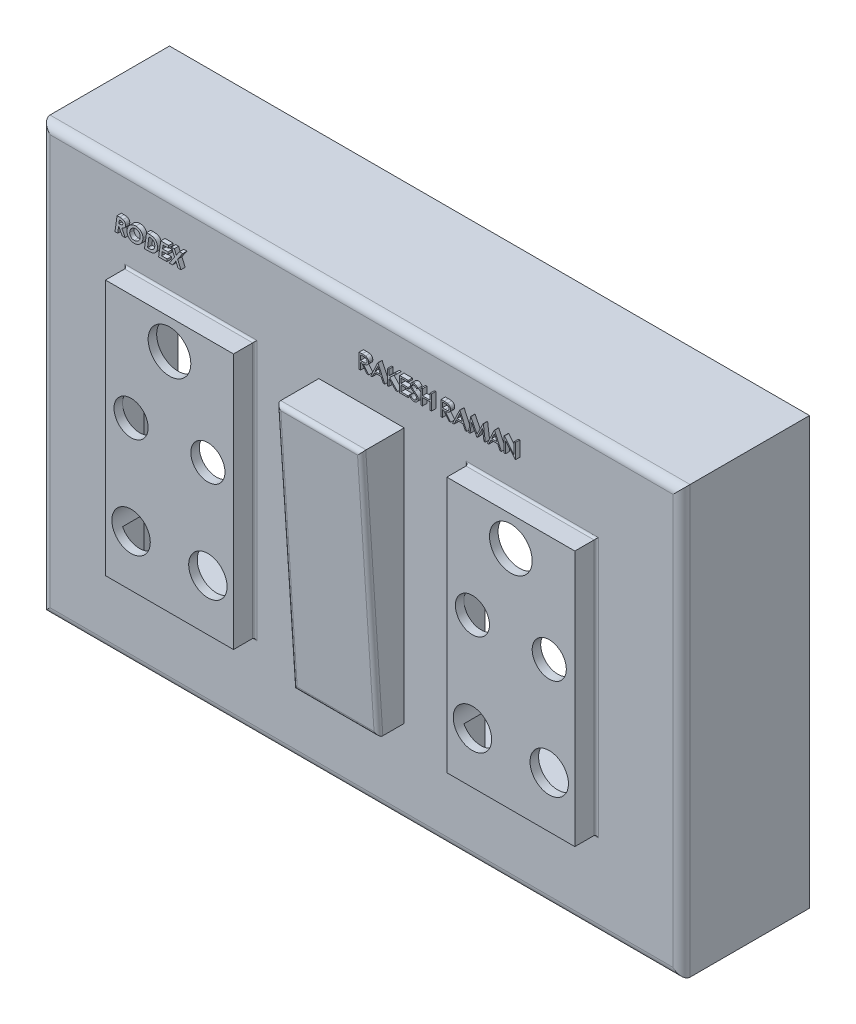
from build123d import *

# Parameters (mm, degrees)
SKETCH1_W           = 150
SKETCH1_H           = 100
BOSS_EXTRUDE1_DEPTH = 30
SKETCH2_W           = 30
SKETCH2_H           = 60
BOSS_EXTRUDE2_DEPTH = 5
LPATTERN1_COUNT     = 2
LPATTERN1_PITCH     = 80
SHELL2_T            = -2
SKETCH3_R           = 5
SKETCH3_R_2         = 4
SKETCH3_R_3         = 4.5
CUT_EXTRUDE1_DEPTH  = 36
BOSS_EXTRUDE3_DEPTH = 10
FILLET1_R           = 2
FILLET2_R           = 0.5
FILLET3_R           = 1
BOSS_EXTRUDE4_DEPTH = 1
BOSS_EXTRUDE5_DEPTH = 1


with BuildPart() as part:
    # Sketch1 → Boss-Extrude1 (new body)
    with BuildSketch(Plane.XY):
        Rectangle(SKETCH1_W, SKETCH1_H)
    extrude(amount=BOSS_EXTRUDE1_DEPTH)

    # Sketch2 → Boss-Extrude2 (add)
    with BuildSketch(Plane.XY.offset(30)):
        with Locations((-40, 0)):
            Rectangle(SKETCH2_W, SKETCH2_H)
    boss_extrude2 = extrude(amount=BOSS_EXTRUDE2_DEPTH)

    # LPattern1: Boss-Extrude2 ×2
    with Locations(*[(i * LPATTERN1_PITCH, 0, 0) for i in range(1, LPATTERN1_COUNT)]):
        add(boss_extrude2)

    # Shell2
    shell2_openings = [part.faces().sort_by_distance(p)[0] for p in [
        (0, 0, 0),
    ]]
    offset(amount=SHELL2_T, openings=shell2_openings, kind=Kind.INTERSECTION)

    # Sketch3 → Cut-Extrude1 (cut)
    with BuildSketch(Plane.XY.offset(35)):
        with Locations((-40, 23)):
            Circle(SKETCH3_R)
        with Locations((-49, 5)):
            Circle(SKETCH3_R_2)
        with Locations((-31, 5)):
            Circle(SKETCH3_R_2)
        with Locations((-49, -18)):
            Circle(SKETCH3_R_3)
        with Locations((-31, -18)):
            Circle(SKETCH3_R_3)
        with Locations((31, 5)):
            Circle(SKETCH3_R_2)
        with Locations((40, 23)):
            Circle(SKETCH3_R)
        with Locations((49, 5)):
            Circle(SKETCH3_R_2)
        with Locations((31, -18)):
            Circle(SKETCH3_R_3)
        with Locations((49, -18)):
            Circle(SKETCH3_R_3)
    extrude(amount=-CUT_EXTRUDE1_DEPTH, mode=Mode.SUBTRACT)

    # Sketch8 → Boss-Extrude3 (add, symmetric)
    with BuildSketch(Plane(origin=(0, 0, 0), x_dir=(0, 0, -1), z_dir=(1, 0, 0))):
        Polygon((-30, 30), (-40, 30), (-36, -30), (-30, -30), align=None)
    extrude(amount=BOSS_EXTRUDE3_DEPTH, both=True)

    # Fillet1
    fillet1_edges = [part.edges().sort_by_distance(p)[0] for p in [
        (-75, 0, 30),
        (0, -50, 30),
        (75, 0, 30),
        (0, 50, 30),
    ]]
    fillet(fillet1_edges, radius=FILLET1_R)

    # Fillet2
    fillet2_edges = [part.edges().sort_by_distance(p)[0] for p in [
        (-25, 0, 30),
        (-40, 30, 30),
        (-55, 0, 30),
        (-40, -30, 30),
        (55, 0, 30),
        (40, 30, 30),
        (25, 0, 30),
        (40, -30, 30),
    ]]
    fillet(fillet2_edges, radius=FILLET2_R)

    # Fillet3
    fillet3_edges = [part.edges().sort_by_distance(p)[0] for p in [
        (-10, 0, 38),
        (0, 30, 40),
        (0, -30, 36),
        (10, 0, 38),
    ]]
    fillet(fillet3_edges, radius=FILLET3_R)

    # Sketch9 → Boss-Extrude4 (add)
    with BuildSketch(Plane.XY.offset(30)):
        Polygon((-43.547393435, 40.422406767), (-42.864500807, 40.422406767), (-42.389841352, 39.346184812), (-41.644548884, 40.422406767), (-40.890842954, 40.422406767), (-42.096071319, 38.681521351), (-41.319929493, 36.922406767), (-42.002120999, 36.922406767), (-42.513238787, 38.079257729), (-43.313919877, 36.922406767), (-44.067625807, 36.922406767), (-42.806307698, 38.743921191), align=None)
        Polygon((-46.053903852, 40.422406767), (-44.16648398, 40.422406767), (-44.240101768, 39.839073434), (-45.501419877, 39.839073434), (-45.615001608, 39.031381126), (-44.341764428, 39.031381126), (-44.416083339, 38.448047793), (-45.697032858, 38.448047793), (-45.828843755, 37.505740101), (-44.534572922, 37.505740101), (-44.608190711, 36.922406767), (-46.544689108, 36.922406767), align=None)
        with BuildLine():
            Line((-49.374416672, 40.422406767), (-48.821932698, 40.422406767))
            add(Edge.make_bspline(
                [(-48.821932698, 40.422406767), (-48.759290387, 40.421889397), (-48.638152322, 40.420888903), (-48.462480874, 40.412639578), (-48.299442504, 40.398079242), (-48.148738887, 40.377926725), (-48.010357772, 40.352215695), (-47.884246306, 40.321082878), (-47.770278799, 40.284251753), (-47.668137679, 40.239998159), (-47.574089919, 40.190339256), (-47.485954252, 40.133676052), (-47.402212683, 40.070716209), (-47.322300496, 40.001858101), (-47.247837539, 39.925589229), (-47.177775921, 39.842713508), (-47.111847466, 39.753410594), (-47.050274592, 39.658607579), (-46.99488923, 39.558371142), (-46.946505843, 39.453604173), (-46.904965724, 39.34530025), (-46.872109833, 39.232864844), (-46.84613627, 39.116935479), (-46.827255044, 38.997060228), (-46.815729294, 38.873389341), (-46.814527877, 38.789752735), (-46.813919877, 38.7474268)],
                knots=[0, 0, 0, 0, 1.508928034, 2.917973822, 4.235011166, 5.450779055, 6.579221784, 7.623755204, 8.577985451, 9.460610614, 10.301756591, 11.137250569, 11.981705789, 12.823774396, 13.675702816, 14.546470419, 15.435981066, 16.347923198, 17.267651715, 18.192054867, 19.125737078, 20.059147693, 21.011116727, 21.985721956, 22.980635317, 24, 24, 24, 24], degree=3))
            add(Edge.make_bspline(
                [(-46.813919877, 38.7474268), (-46.814774157, 38.70369732), (-46.816472156, 38.616778874), (-46.828656039, 38.487976676), (-46.848359824, 38.361782887), (-46.875519412, 38.238241361), (-46.911289505, 38.117302821), (-46.95595236, 37.999604468), (-47.006807136, 37.883969064), (-47.066568068, 37.772774746), (-47.131016482, 37.666011074), (-47.200793477, 37.566182849), (-47.2739781, 37.473397811), (-47.352410576, 37.388928871), (-47.43458433, 37.311572308), (-47.520529875, 37.241329906), (-47.611174378, 37.17917603), (-47.706415878, 37.124006463), (-47.808790036, 37.075645841), (-47.919864089, 37.034677438), (-48.039979404, 36.999465995), (-48.169710895, 36.97197737), (-48.308439698, 36.949536922), (-48.456561442, 36.93346408), (-48.61405927, 36.924665187), (-48.72212911, 36.923174271), (-48.777762025, 36.922406767)],
                knots=[0, 0, 0, 0, 1.035326767, 2.057856534, 3.060426681, 4.057975219, 5.050723532, 6.043595218, 7.036960241, 8.039530388, 9.030318104, 9.988216712, 10.921569661, 11.826132526, 12.714780289, 13.59198308, 14.451536877, 15.31430869, 16.195534129, 17.128821459, 18.114698389, 19.15667332, 20.266554844, 21.441073174, 22.682698532, 24, 24, 24, 24], degree=3))
            Line((-48.777762025, 36.922406767), (-49.865201928, 36.922406767))
            Line((-49.865201928, 36.922406767), (-49.374416672, 40.422406767))
        make_face()
        with BuildLine():
            Line((-48.822633819, 39.839073434), (-49.149356576, 37.505740101))
            Line((-49.149356576, 37.505740101), (-48.922894236, 37.505740101))
            add(Edge.make_bspline(
                [(-48.922894236, 37.505740101), (-48.880821073, 37.505955589), (-48.799924163, 37.506369924), (-48.683066021, 37.511008387), (-48.575191276, 37.516530336), (-48.47635572, 37.526783879), (-48.386198218, 37.538193292), (-48.305331211, 37.553057707), (-48.232824593, 37.569034943), (-48.188711057, 37.584120985), (-48.167786063, 37.59127696)],
                knots=[0, 0, 0, 0, 1.323091274, 2.54399687, 3.677836413, 4.719289959, 5.668358043, 6.534823038, 7.305002022, 8, 8, 8, 8], degree=3))
            add(Edge.make_bspline(
                [(-48.167786063, 37.59127696), (-48.140899852, 37.60172672), (-48.087487917, 37.622486132), (-48.012162341, 37.662867302), (-47.939077552, 37.705666553), (-47.871429396, 37.756008508), (-47.806819913, 37.810655894), (-47.7478338, 37.871943474), (-47.691607404, 37.93761707), (-47.640133478, 38.008941608), (-47.593076254, 38.084773082), (-47.553002495, 38.165704603), (-47.518399787, 38.250660786), (-47.490691839, 38.340343711), (-47.468737841, 38.434045283), (-47.453739247, 38.532043712), (-47.443267845, 38.634319362), (-47.442510501, 38.704163236), (-47.442125005, 38.73971446)],
                knots=[0, 0, 0, 0, 0.952655881, 1.892538673, 2.821337892, 3.750040712, 4.676008024, 5.615700279, 6.558436491, 7.532008524, 8.520486916, 9.505184105, 10.513747313, 11.549809891, 12.604882282, 13.692134403, 14.825273528, 16, 16, 16, 16], degree=3))
            add(Edge.make_bspline(
                [(-47.442125005, 38.73971446), (-47.442527846, 38.768937256), (-47.443315176, 38.826051573), (-47.449501743, 38.909912287), (-47.460968386, 38.990150986), (-47.475976013, 39.06681252), (-47.495922348, 39.139829917), (-47.519690861, 39.209187915), (-47.547380566, 39.275388702), (-47.591695881, 39.357046521), (-47.654863795, 39.452315716), (-47.747138857, 39.55301225), (-47.854370035, 39.639033943), (-47.954320488, 39.699148793), (-48.041548257, 39.740282487), (-48.113185574, 39.766621303), (-48.189991294, 39.789231233), (-48.272098349, 39.806937164), (-48.359022943, 39.82214953), (-48.45135934, 39.831270574), (-48.548862394, 39.838026458), (-48.615789667, 39.838718209), (-48.650157858, 39.839073434)],
                knots=[0, 0, 0, 0, 0.941373656, 1.839862062, 2.706559874, 3.551131217, 4.354742518, 5.142827075, 5.911946928, 6.663057697, 8.133107042, 9.582556681, 11.0440985, 12.547036792, 13.328439944, 14.147940985, 15.003216405, 15.905576335, 16.852443473, 17.844335315, 18.893032825, 20, 20, 20, 20], degree=3))
            Line((-48.650157858, 39.839073434), (-48.822633819, 39.839073434))
        make_face(mode=Mode.SUBTRACT)
        with BuildLine():
            add(Edge.make_bspline(
                [(-51.887938307, 40.512150357), (-51.828973482, 40.510912856), (-51.713197802, 40.508483058), (-51.543495377, 40.486123035), (-51.381595874, 40.450083299), (-51.227893755, 40.398403173), (-51.081798878, 40.333114436), (-50.943662788, 40.252654398), (-50.813636321, 40.157590939), (-50.692778193, 40.04921214), (-50.583303738, 39.929798172), (-50.486222935, 39.801987961), (-50.405598379, 39.665200149), (-50.339201848, 39.520957911), (-50.286861811, 39.36910353), (-50.251158378, 39.208907266), (-50.227591277, 39.041430589), (-50.22532858, 38.926996939), (-50.224176287, 38.86872087)],
                knots=[0, 0, 0, 0, 1.079937363, 2.120424901, 3.130164457, 4.114608815, 5.086352068, 6.057283592, 7.037967613, 8.032612779, 9.026667848, 10.002130715, 10.967845321, 11.92966918, 12.907375778, 13.904589319, 14.932898699, 16, 16, 16, 16], degree=3))
            add(Edge.make_bspline(
                [(-50.224176287, 38.86872087), (-50.224914256, 38.823347653), (-50.226382019, 38.733103842), (-50.240348474, 38.598920423), (-50.262106322, 38.466641272), (-50.291897994, 38.336228211), (-50.331777104, 38.208099516), (-50.379380003, 38.081496037), (-50.436168473, 37.956935761), (-50.501386974, 37.83538348), (-50.572832347, 37.718270982), (-50.651140848, 37.607532431), (-50.73526803, 37.50382504), (-50.824891022, 37.406740524), (-50.920977573, 37.317578589), (-51.021649634, 37.234471365), (-51.129088084, 37.159307899), (-51.24158734, 37.090652264), (-51.359382524, 37.0296357), (-51.481677665, 36.976898587), (-51.608313599, 36.932805542), (-51.738991311, 36.896352114), (-51.87403357, 36.867351248), (-52.013415372, 36.847317452), (-52.157185612, 36.835159151), (-52.254367308, 36.833503634), (-52.303703531, 36.832663178)],
                knots=[0, 0, 0, 0, 1.005311864, 1.999487392, 2.986390894, 3.975195422, 4.961487101, 5.958115224, 6.97104375, 7.992937587, 9.013623077, 10.009524137, 10.996414046, 11.971324635, 12.935123389, 13.899409138, 14.862205298, 15.838449601, 16.81836937, 17.799766407, 18.787539403, 19.787875373, 20.804768927, 21.846385261, 22.906674593, 24, 24, 24, 24], degree=3))
            add(Edge.make_bspline(
                [(-52.303703531, 36.832663178), (-52.364768061, 36.833921598), (-52.484003636, 36.83637881), (-52.657781328, 36.858080815), (-52.822200652, 36.89196513), (-52.977269185, 36.94047307), (-53.123275806, 37.003023262), (-53.259738688, 37.079774766), (-53.386991965, 37.169890765), (-53.5029024, 37.274010014), (-53.608300432, 37.388219062), (-53.6988067, 37.51346756), (-53.776964198, 37.646374147), (-53.83897103, 37.789116583), (-53.888587491, 37.939943218), (-53.923155991, 38.099721681), (-53.944773705, 38.268200553), (-53.94726236, 38.383477002), (-53.948535262, 38.442438819)],
                knots=[0, 0, 0, 0, 1.129126937, 2.20475128, 3.23403939, 4.230775744, 5.204839333, 6.16680792, 7.121629951, 8.083044708, 9.04383724, 9.990659777, 10.936010704, 11.890255174, 12.863608629, 13.868449271, 14.909750384, 16, 16, 16, 16], degree=3))
            add(Edge.make_bspline(
                [(-53.948535262, 38.442438819), (-53.94700596, 38.509834945), (-53.943994684, 38.642541521), (-53.917523901, 38.837884118), (-53.877062598, 39.026442562), (-53.817444786, 39.207214961), (-53.742258443, 39.380887275), (-53.649653055, 39.546881264), (-53.541063492, 39.706542953), (-53.456404006, 39.80479679), (-53.413579332, 39.854498114)],
                knots=[0, 0, 0, 0, 1.045740506, 2.05911896, 3.05467723, 4.035585325, 5.008815224, 5.988058098, 6.982266978, 8, 8, 8, 8], degree=3))
            add(Edge.make_bspline(
                [(-53.413579332, 39.854498114), (-53.388649769, 39.881445822), (-53.339239492, 39.934856052), (-53.26016141, 40.0090792), (-53.179147553, 40.078570119), (-53.095051188, 40.142503863), (-53.009142418, 40.202365344), (-52.920052286, 40.256267874), (-52.828117799, 40.30479636), (-52.734338831, 40.349048024), (-52.637101807, 40.386832196), (-52.538087519, 40.420686836), (-52.435921883, 40.448620076), (-52.331324949, 40.471739845), (-52.22419659, 40.490123098), (-52.114394475, 40.502460586), (-52.002105406, 40.510444616), (-51.926280011, 40.511577504), (-51.887938307, 40.512150357)],
                knots=[0, 0, 0, 0, 1.027812829, 2.037120149, 3.035266778, 4.015768311, 4.994345575, 5.966422343, 6.929711672, 7.904780536, 8.86860337, 9.849672715, 10.834163809, 11.833018336, 12.848777673, 13.876590502, 14.926281379, 16, 16, 16, 16], degree=3))
        make_face()
        with BuildLine():
            add(Edge.make_bspline(
                [(-51.902661864, 39.928817024), (-51.934468876, 39.928341515), (-51.997748676, 39.927395494), (-52.091410195, 39.917881855), (-52.183187476, 39.903141277), (-52.2726949, 39.882940165), (-52.360361901, 39.856868442), (-52.445591612, 39.824648747), (-52.529013746, 39.786517991), (-52.609708584, 39.742519131), (-52.687946826, 39.693454287), (-52.762094746, 39.638697128), (-52.832673739, 39.579031525), (-52.898495837, 39.513405532), (-52.961006455, 39.44316759), (-53.020030604, 39.368175831), (-53.074831094, 39.287699865), (-53.125651665, 39.203078321), (-53.170764142, 39.11500521), (-53.210834054, 39.02619021), (-53.244936146, 38.936620677), (-53.27198113, 38.846053076), (-53.294058846, 38.754850474), (-53.309367715, 38.662772577), (-53.318872989, 38.570012212), (-53.319843905, 38.507899443), (-53.320330134, 38.476793787)],
                knots=[0, 0, 0, 0, 1.015557909, 2.02044445, 3.003357477, 3.982977463, 4.948851735, 5.922052592, 6.890662853, 7.875953625, 8.855459861, 9.837777552, 10.817397539, 11.804383193, 12.803598646, 13.818964529, 14.849984807, 15.911175445, 16.969421976, 18.008462528, 19.021851172, 20.027762868, 21.025304218, 22.016795393, 23.006824523, 24, 24, 24, 24], degree=3))
            add(Edge.make_bspline(
                [(-53.320330134, 38.476793787), (-53.319562512, 38.44052815), (-53.318052176, 38.369173524), (-53.304891358, 38.264135147), (-53.284499951, 38.16300844), (-53.253643325, 38.066631534), (-53.216149774, 37.973962383), (-53.168545797, 37.886385994), (-53.113822605, 37.802170699), (-53.050220609, 37.723455673), (-52.979180754, 37.650780593), (-52.899035485, 37.588080792), (-52.811824072, 37.534542771), (-52.717171954, 37.490977031), (-52.615157118, 37.456974062), (-52.505517228, 37.433868331), (-52.388734727, 37.418557113), (-52.308428814, 37.416864527), (-52.267245198, 37.415996511)],
                knots=[0, 0, 0, 0, 1.032572517, 2.031642993, 3.01079972, 3.966643664, 4.909863955, 5.853952978, 6.801111379, 7.766917104, 8.731873648, 9.689385086, 10.65752794, 11.640388645, 12.650815691, 13.713650281, 14.827481725, 16, 16, 16, 16], degree=3))
            add(Edge.make_bspline(
                [(-52.267245198, 37.415996511), (-52.219036144, 37.417135556), (-52.123842293, 37.419384721), (-51.984019218, 37.439417341), (-51.849795446, 37.472672277), (-51.721159455, 37.518115565), (-51.598069804, 37.576932899), (-51.480523442, 37.648718234), (-51.368823664, 37.73415636), (-51.263869016, 37.831012497), (-51.167455615, 37.93672827), (-51.083177299, 38.049710473), (-51.011604854, 38.168471614), (-50.953292589, 38.292751995), (-50.908174393, 38.422760808), (-50.876011253, 38.558269632), (-50.855714418, 38.699369501), (-50.853501841, 38.795501427), (-50.852381416, 38.844181607)],
                knots=[0, 0, 0, 0, 1.03369803, 2.041145535, 3.022357397, 3.995919545, 4.96236968, 5.943376615, 6.945032455, 7.973917545, 9.003120129, 10.009769043, 10.992465341, 11.972511115, 12.949140339, 13.93890809, 14.956285095, 16, 16, 16, 16], degree=3))
            add(Edge.make_bspline(
                [(-50.852381416, 38.844181607), (-50.853027787, 38.884191879), (-50.85429453, 38.962602983), (-50.868920783, 39.076782215), (-50.891138573, 39.185004447), (-50.922370895, 39.287236229), (-50.964438443, 39.382902417), (-51.01379099, 39.47318065), (-51.073560722, 39.556539334), (-51.141292992, 39.633254071), (-51.216176709, 39.702960503), (-51.297856902, 39.763061959), (-51.384557445, 39.815244394), (-51.477761173, 39.855954747), (-51.575781577, 39.889721393), (-51.679773999, 39.912422897), (-51.789428773, 39.925829268), (-51.864295063, 39.927804682), (-51.902661864, 39.928817024)],
                knots=[0, 0, 0, 0, 1.12845219, 2.211511647, 3.242392028, 4.243671568, 5.221368115, 6.186708094, 7.141970352, 8.109200861, 9.070590294, 10.022934043, 10.966237583, 11.91979086, 12.887493425, 13.887534174, 14.917422563, 16, 16, 16, 16], degree=3))
        make_face(mode=Mode.SUBTRACT)
        with BuildLine():
            Line((-56.284673082, 40.422406767), (-55.676800486, 40.422406767))
            add(Edge.make_bspline(
                [(-55.676800486, 40.422406767), (-55.631689768, 40.422222419), (-55.54471088, 40.421866974), (-55.41963241, 40.416812548), (-55.304831654, 40.409186975), (-55.200445114, 40.399123522), (-55.106385638, 40.385161044), (-55.022848829, 40.368396292), (-54.949301119, 40.349726404), (-54.905194816, 40.332377127), (-54.884532858, 40.324249716)],
                knots=[0, 0, 0, 0, 1.348808202, 2.600664361, 3.742342956, 4.788858012, 5.735658768, 6.584006912, 7.336666444, 8, 8, 8, 8], degree=3))
            add(Edge.make_bspline(
                [(-54.884532858, 40.324249716), (-54.86127015, 40.313759346), (-54.815795237, 40.293252333), (-54.750632337, 40.258491686), (-54.689612353, 40.221045036), (-54.633746582, 40.179500521), (-54.581856083, 40.135607447), (-54.534262624, 40.088948332), (-54.491349433, 40.038807103), (-54.452666143, 39.98608311), (-54.418269129, 39.930844544), (-54.388742837, 39.872819007), (-54.363211963, 39.81249776), (-54.343274467, 39.749224402), (-54.326704011, 39.683758458), (-54.315986841, 39.615686882), (-54.308444602, 39.545239292), (-54.307824861, 39.497414587), (-54.307509621, 39.473087857)],
                knots=[0, 0, 0, 0, 1.116361014, 2.182309107, 3.229450697, 4.24598407, 5.225421932, 6.201651319, 7.158895679, 8.110002388, 9.060669178, 10.002827475, 10.956240434, 11.923213192, 12.902917952, 13.908279153, 14.936015885, 16, 16, 16, 16], degree=3))
            add(Edge.make_bspline(
                [(-54.307509621, 39.473087857), (-54.308250987, 39.443152142), (-54.309714563, 39.384054195), (-54.319277878, 39.296906321), (-54.33711465, 39.213278889), (-54.361135401, 39.132908464), (-54.390895184, 39.055274657), (-54.429274317, 38.981728354), (-54.473635822, 38.910988101), (-54.524868834, 38.843981348), (-54.582134059, 38.780093417), (-54.648255331, 38.723084184), (-54.719574727, 38.669119618), (-54.799022149, 38.621817803), (-54.884412596, 38.577878629), (-54.977693704, 38.540650691), (-55.077114731, 38.50629505), (-55.146826943, 38.48910053), (-55.182509621, 38.480299396)],
                knots=[0, 0, 0, 0, 0.995453645, 1.965186658, 2.910129054, 3.83459069, 4.752398018, 5.669942118, 6.588407184, 7.525617038, 8.471772905, 9.435289717, 10.423772802, 11.441988612, 12.505459691, 13.613754905, 14.778583949, 16, 16, 16, 16], degree=3))
            Line((-55.182509621, 38.480299396), (-54.374817313, 36.922406767))
            Line((-54.374817313, 36.922406767), (-55.07664023, 36.922406767))
            Line((-55.07664023, 36.922406767), (-55.867505614, 38.448047793))
            Line((-55.867505614, 38.448047793), (-55.927100967, 38.448047793))
            Line((-55.927100967, 38.448047793), (-56.141644236, 36.922406767))
            Line((-56.141644236, 36.922406767), (-56.775458339, 36.922406767))
            Line((-56.775458339, 36.922406767), (-56.284673082, 40.422406767))
        make_face()
        with BuildLine():
            add(Edge.make_bspline(
                [(-55.845069717, 39.031381126), (-55.799957643, 39.031800016), (-55.713669594, 39.032601247), (-55.590433204, 39.038174389), (-55.479302411, 39.046977929), (-55.380597716, 39.059558763), (-55.294059473, 39.074437337), (-55.220055301, 39.093012173), (-55.158245998, 39.115097316), (-55.107656675, 39.141288089), (-55.066675838, 39.172038612), (-55.031205164, 39.20485424), (-55.001669446, 39.241587703), (-54.977299831, 39.281622322), (-54.95850435, 39.325041078), (-54.944949903, 39.372138126), (-54.937455542, 39.422599442), (-54.936303444, 39.457405922), (-54.935714749, 39.475191223)],
                knots=[0, 0, 0, 0, 1.892208387, 3.619318591, 5.173427176, 6.566868293, 7.791773198, 8.8545744, 9.763297566, 10.539470204, 11.233547833, 11.906251103, 12.5615143, 13.203742025, 13.866659999, 14.539934446, 15.25394049, 16, 16, 16, 16], degree=3))
            add(Edge.make_bspline(
                [(-54.935714749, 39.475191223), (-54.936476792, 39.495357186), (-54.93795505, 39.53447639), (-54.950741384, 39.590819324), (-54.972605574, 39.641930019), (-55.003332714, 39.687319831), (-55.041678533, 39.727342321), (-55.08845833, 39.760305458), (-55.143137568, 39.786253789), (-55.194358971, 39.803397065), (-55.242842714, 39.81332689), (-55.288038904, 39.819998402), (-55.341549931, 39.826436173), (-55.403536753, 39.831196702), (-55.473924853, 39.834345703), (-55.552678396, 39.837405635), (-55.639638504, 39.838493764), (-55.700405077, 39.838874362), (-55.732189108, 39.839073434)],
                knots=[0, 0, 0, 0, 0.974340854, 1.890087692, 2.776057671, 3.647490651, 4.526730822, 5.442477659, 6.397820337, 7.445016909, 8.045730266, 8.789007992, 9.653967296, 10.651691253, 11.794598421, 13.061237498, 14.462876682, 16, 16, 16, 16], degree=3))
            Line((-55.732189108, 39.839073434), (-55.845069717, 39.031381126))
        make_face(mode=Mode.SUBTRACT)
    extrude(amount=BOSS_EXTRUDE4_DEPTH)

    # Sketch10 → Boss-Extrude5 (add)
    with BuildSketch(Plane.XY.offset(30)):
        with BuildLine():
            Line((0.448717949, 41.093484585), (1.149138622, 41.093484585))
            add(Edge.make_bspline(
                [(1.149138622, 41.093484585), (1.19587975, 41.093328999), (1.285627895, 41.093030257), (1.414201165, 41.091364494), (1.531028262, 41.086590138), (1.636048101, 41.082481554), (1.729258756, 41.074989613), (1.810946047, 41.067828966), (1.880733745, 41.058455305), (1.922979596, 41.049749882), (1.942107372, 41.045808303)],
                knots=[0, 0, 0, 0, 1.410062039, 2.707475311, 3.878576406, 4.937260626, 5.877586885, 6.699081471, 7.410979367, 8, 8, 8, 8], degree=3))
            add(Edge.make_bspline(
                [(1.942107372, 41.045808303), (1.967713996, 41.039481537), (2.018380985, 41.026962974), (2.091331051, 41.000503373), (2.160845375, 40.969883748), (2.2266352, 40.933920028), (2.288370991, 40.892345248), (2.346689302, 40.845877126), (2.401854765, 40.79476992), (2.451636395, 40.737735079), (2.498575447, 40.677898569), (2.538164073, 40.613194812), (2.572290553, 40.545533285), (2.59946107, 40.474225867), (2.621339044, 40.399964095), (2.636765283, 40.322075298), (2.646016471, 40.240914323), (2.646958326, 40.185556414), (2.647435897, 40.157486989)],
                knots=[0, 0, 0, 0, 1.027469482, 2.033020251, 3.019912614, 3.986113645, 4.951240523, 5.91722682, 6.890402269, 7.87763091, 8.8651537, 9.85103654, 10.82876324, 11.815024772, 12.821070561, 13.842952187, 14.906261191, 16, 16, 16, 16], degree=3))
            add(Edge.make_bspline(
                [(2.647435897, 40.157486989), (2.645966899, 40.110851884), (2.643100504, 40.019854716), (2.6163754, 39.887793835), (2.57259888, 39.76460452), (2.512275591, 39.650441882), (2.435456115, 39.547531237), (2.343131324, 39.457140782), (2.235249713, 39.381500869), (2.134820397, 39.329048064), (2.046106197, 39.295455156), (1.973072884, 39.271818797), (1.893405907, 39.253556832), (1.807868572, 39.2371967), (1.716104917, 39.224845005), (1.618334877, 39.215798411), (1.514488726, 39.210144362), (1.443149656, 39.209302357), (1.406450321, 39.2088692)],
                knots=[0, 0, 0, 0, 1.260483769, 2.459530307, 3.627416485, 4.787058657, 5.939039949, 7.08810263, 8.267026773, 9.491475466, 10.141966685, 10.831826277, 11.566392101, 12.351337768, 13.187381173, 14.07005841, 15.007169909, 16, 16, 16, 16], degree=3))
            Line((1.406450321, 39.2088692), (2.692307692, 37.593484585))
            Line((2.692307692, 37.593484585), (2.303886218, 37.593484585))
            Line((2.303886218, 37.593484585), (1.018028846, 39.2088692))
            Line((1.018028846, 39.2088692), (0.762820513, 39.2088692))
            Line((0.762820513, 39.2088692), (0.762820513, 37.593484585))
            Line((0.762820513, 37.593484585), (0.448717949, 37.593484585))
            Line((0.448717949, 37.593484585), (0.448717949, 41.093484585))
        make_face()
        with BuildLine():
            Line((0.762820513, 40.734510226), (0.762820513, 39.567843559))
            Line((0.762820513, 39.567843559), (1.403645833, 39.562935707))
            add(Edge.make_bspline(
                [(1.403645833, 39.562935707), (1.433565872, 39.56292247), (1.491559429, 39.562896814), (1.575460094, 39.56689059), (1.653580206, 39.571433908), (1.725620958, 39.578383254), (1.791614533, 39.587339325), (1.851527947, 39.59854231), (1.905458998, 39.611594372), (1.968357537, 39.631795998), (2.038594068, 39.663802016), (2.114925528, 39.710367515), (2.179927866, 39.768936634), (2.234845728, 39.83591009), (2.27897516, 39.909546339), (2.310087214, 39.988962708), (2.329829656, 40.072154306), (2.332158202, 40.129332414), (2.333333333, 40.158188111)],
                knots=[0, 0, 0, 0, 1.146690395, 2.22261258, 3.21895312, 4.145990853, 4.996080663, 5.770904154, 6.481378293, 7.121626537, 8.300444488, 9.431385265, 10.535395872, 11.636531494, 12.74115979, 13.810798291, 14.895190096, 16, 16, 16, 16], degree=3))
            add(Edge.make_bspline(
                [(2.333333333, 40.158188111), (2.332131212, 40.186334684), (2.329749047, 40.242110923), (2.310300278, 40.323766833), (2.277410897, 40.400833783), (2.233088659, 40.472998268), (2.179089504, 40.538504004), (2.115771691, 40.594551157), (2.044866496, 40.640800622), (1.978595298, 40.670355002), (1.919361085, 40.688474856), (1.867931425, 40.70122602), (1.809819948, 40.711470488), (1.744744489, 40.719678549), (1.672982858, 40.726733494), (1.594172207, 40.731485272), (1.508835427, 40.734299136), (1.449688496, 40.734438225), (1.419070513, 40.734510226)],
                knots=[0, 0, 0, 0, 1.101028733, 2.181837193, 3.264309656, 4.369019818, 5.486613113, 6.575447106, 7.666700264, 8.788928104, 9.402425223, 10.0903467, 10.862060571, 11.710948788, 12.657782767, 13.684531032, 14.801375019, 16, 16, 16, 16], degree=3))
            Line((1.419070513, 40.734510226), (0.762820513, 40.734510226))
        make_face(mode=Mode.SUBTRACT)
        Polygon((4.846153846, 41.093484585), (6.461538462, 37.593484585), (6.120092147, 37.593484585), (5.602664263, 38.715279457), (4.016025641, 38.715279457), (3.483874199, 37.593484585), (3.141025641, 37.593484585), (4.801282051, 41.093484585), align=None)
        Polygon((4.82021234, 40.411293078), (4.186398237, 39.074253816), (5.437199519, 39.074253816), align=None, mode=Mode.SUBTRACT)
        Polygon((7.08974359, 41.093484585), (7.403846154, 41.093484585), (7.403846154, 39.760652053), (8.862880609, 41.093484585), (9.310897436, 41.093484585), (7.591045673, 39.522971764), (9.445512821, 37.593484585), (9.026943109, 37.593484585), (7.403846154, 39.282486989), (7.403846154, 37.593484585), (7.08974359, 37.593484585), align=None)
        Polygon((9.961538462, 41.093484585), (11.935897436, 41.093484585), (11.935897436, 40.734510226), (10.275641026, 40.734510226), (10.275641026, 39.657587149), (11.935897436, 39.657587149), (11.935897436, 39.29861279), (10.275641026, 39.29861279), (10.275641026, 37.952458944), (11.935897436, 37.952458944), (11.935897436, 37.593484585), (9.961538462, 37.593484585), align=None)
        with BuildLine():
            Line((12.205128205, 38.268664873), (12.501001603, 38.446048687))
            add(Edge.make_bspline(
                [(12.501001603, 38.446048687), (12.52851984, 38.399984303), (12.58124372, 38.311726719), (12.66919508, 38.192468678), (12.760327991, 38.091106521), (12.855317324, 38.008229914), (12.953583272, 37.942981027), (13.055767326, 37.896778795), (13.161525137, 37.86796282), (13.233498958, 37.864462733), (13.26943109, 37.862715354)],
                knots=[0, 0, 0, 0, 1.272034388, 2.437168799, 3.508375237, 4.49857839, 5.41946034, 6.295179144, 7.148887113, 8, 8, 8, 8], degree=3))
            add(Edge.make_bspline(
                [(13.26943109, 37.862715354), (13.30011795, 37.863570027), (13.360954723, 37.865264417), (13.450516966, 37.881545219), (13.537498769, 37.906557348), (13.620107406, 37.942378279), (13.697203021, 37.985716765), (13.764809716, 38.038062943), (13.823255829, 38.096669148), (13.871064944, 38.162051803), (13.907744979, 38.232368952), (13.935937048, 38.304544903), (13.951582121, 38.379713471), (13.953938875, 38.430323934), (13.955128205, 38.455864393)],
                knots=[0, 0, 0, 0, 1.095163259, 2.171163733, 3.241058638, 4.321873601, 5.38011039, 6.391990106, 7.366004449, 8.327778327, 9.272591725, 10.192022065, 11.087607919, 12, 12, 12, 12], degree=3))
            add(Edge.make_bspline(
                [(13.955128205, 38.455864393), (13.953653894, 38.485005242), (13.950656836, 38.544244331), (13.925325356, 38.631643984), (13.885476109, 38.718136554), (13.848713466, 38.77163782), (13.829627404, 38.799414072)],
                knots=[0, 0, 0, 0, 0.938893495, 1.908633276, 2.914225137, 4, 4, 4, 4], degree=3))
            add(Edge.make_bspline(
                [(13.829627404, 38.799414072), (13.81395679, 38.819460896), (13.781058295, 38.861546694), (13.724500783, 38.92419193), (13.658134668, 38.988810349), (13.584231114, 39.057869406), (13.500098025, 39.128157202), (13.40837051, 39.20302548), (13.306706651, 39.279627057), (13.235407155, 39.330999623), (13.198617788, 39.357507021)],
                knots=[0, 0, 0, 0, 0.722233717, 1.516239348, 2.393582979, 3.351407094, 4.387010283, 5.505090956, 6.712668013, 8, 8, 8, 8], degree=3))
            add(Edge.make_bspline(
                [(13.198617788, 39.357507021), (13.161793792, 39.383735608), (13.091389116, 39.433882671), (12.992930533, 39.508306955), (12.90488607, 39.576350824), (12.827647054, 39.638654836), (12.761247457, 39.695227441), (12.705164046, 39.74552538), (12.660825489, 39.790908941), (12.636169908, 39.820350283), (12.62510016, 39.83356872)],
                knots=[0, 0, 0, 0, 1.452282411, 2.77665338, 3.964542531, 5.026858415, 5.96415736, 6.766646006, 7.446254459, 8, 8, 8, 8], degree=3))
            add(Edge.make_bspline(
                [(12.62510016, 39.83356872), (12.609627615, 39.854169756), (12.579198778, 39.89468446), (12.539032773, 39.958009318), (12.50489361, 40.022832583), (12.478131278, 40.089328448), (12.455595059, 40.156563377), (12.440437128, 40.225414622), (12.430945731, 40.295573241), (12.429973745, 40.342786742), (12.429487179, 40.366421284)],
                knots=[0, 0, 0, 0, 1.068054152, 2.10047183, 3.106115577, 4.101338837, 5.06977816, 6.043150881, 7.020423561, 8, 8, 8, 8], degree=3))
            add(Edge.make_bspline(
                [(12.429487179, 40.366421284), (12.430792388, 40.403451058), (12.433374909, 40.476719122), (12.455215426, 40.583749952), (12.489688319, 40.68593637), (12.537983207, 40.782266703), (12.60024056, 40.870232684), (12.672286535, 40.950846171), (12.758098021, 41.018614753), (12.852250644, 41.077826812), (12.955307016, 41.124172737), (13.06329792, 41.159133717), (13.176394992, 41.178942975), (13.252998126, 41.18178574), (13.291866987, 41.183228175)],
                knots=[0, 0, 0, 0, 1.005424448, 1.989358655, 2.955360095, 3.929531133, 4.905563448, 5.876582895, 6.856512386, 7.866279853, 8.892233794, 9.918561126, 10.94386622, 12, 12, 12, 12], degree=3))
            add(Edge.make_bspline(
                [(13.291866987, 41.183228175), (13.333111087, 41.181805623), (13.415132439, 41.178976622), (13.535781655, 41.154379091), (13.651942371, 41.113678419), (13.745385636, 41.067489761), (13.818518397, 41.021358345), (13.87429113, 40.979338521), (13.930808581, 40.930963412), (13.988526636, 40.876104166), (14.046467295, 40.814257415), (14.105490747, 40.745846726), (14.165735016, 40.67129017), (14.204490876, 40.61806567), (14.224358974, 40.590780258)],
                knots=[0, 0, 0, 0, 1.286793592, 2.559021753, 3.825965368, 5.121522368, 5.803751409, 6.523245864, 7.299691795, 8.125521123, 9.008227632, 9.944561021, 10.946284179, 12, 12, 12, 12], degree=3))
            Line((14.224358974, 40.590780258), (13.940404647, 40.375535867))
            add(Edge.make_bspline(
                [(13.940404647, 40.375535867), (13.923258715, 40.397624557), (13.890239658, 40.440162211), (13.840110171, 40.499733526), (13.792861523, 40.554150006), (13.746311123, 40.601415134), (13.702917492, 40.644117267), (13.66080045, 40.680677024), (13.620566098, 40.711452619), (13.569849188, 40.744296179), (13.506131469, 40.776852683), (13.426146933, 40.804401761), (13.342560658, 40.820956823), (13.285631027, 40.82314571), (13.256810897, 40.824253816)],
                knots=[0, 0, 0, 0, 1.181633172, 2.275549214, 3.290209073, 4.226197932, 5.078386478, 5.862611352, 6.581680152, 7.217281963, 8.414376989, 9.595101626, 10.782541182, 12, 12, 12, 12], degree=3))
            add(Edge.make_bspline(
                [(13.256810897, 40.824253816), (13.220654375, 40.823042116), (13.150929928, 40.820705467), (13.051939692, 40.795185481), (12.962845766, 40.755003621), (12.886293201, 40.698688643), (12.822556224, 40.63196765), (12.776450766, 40.555188795), (12.748700601, 40.470406392), (12.745314321, 40.411264736), (12.743589744, 40.381144841)],
                knots=[0, 0, 0, 0, 1.14458467, 2.207223713, 3.21896685, 4.227309161, 5.202851033, 6.127160689, 7.046193047, 8, 8, 8, 8], degree=3))
            add(Edge.make_bspline(
                [(12.743589744, 40.381144841), (12.74398287, 40.362393363), (12.744769766, 40.324859743), (12.755744564, 40.269408321), (12.769843893, 40.214096982), (12.792186525, 40.159174399), (12.823031828, 40.10368004), (12.863537004, 40.046658303), (12.914550316, 39.987606594), (12.953627329, 39.94919922), (12.974258814, 39.928921284)],
                knots=[0, 0, 0, 0, 0.858281714, 1.717966888, 2.583508476, 3.4729293, 4.427298488, 5.488583878, 6.674047936, 8, 8, 8, 8], degree=3))
            add(Edge.make_bspline(
                [(12.974258814, 39.928921284), (12.981920187, 39.922084258), (13.000121854, 39.905841049), (13.033397779, 39.879248769), (13.077340578, 39.846445997), (13.130802779, 39.80585868), (13.194770141, 39.758777218), (13.269249697, 39.705803606), (13.35341123, 39.645218147), (13.413133145, 39.602860606), (13.444711538, 39.580463752)],
                knots=[0, 0, 0, 0, 0.420754252, 0.999615792, 1.744751191, 2.668019286, 3.750313428, 4.999500688, 6.413464383, 8, 8, 8, 8], degree=3))
            add(Edge.make_bspline(
                [(13.444711538, 39.580463752), (13.482697452, 39.552822392), (13.556251908, 39.49929873), (13.660909488, 39.41888305), (13.755803296, 39.340235282), (13.8412665, 39.263857675), (13.918143408, 39.190329582), (13.985581129, 39.118766401), (14.044266809, 39.049680829), (14.107446028, 38.961108253), (14.172003847, 38.852327169), (14.227445355, 38.71904893), (14.262403702, 38.58525261), (14.266975217, 38.495325773), (14.269230769, 38.45095654)],
                knots=[0, 0, 0, 0, 1.163667725, 2.253281268, 3.268753668, 4.215851969, 5.092017293, 5.902905408, 6.650798638, 7.335211899, 8.59617414, 9.77448103, 10.901945474, 12, 12, 12, 12], degree=3))
            add(Edge.make_bspline(
                [(14.269230769, 38.45095654), (14.268573631, 38.419578175), (14.267272116, 38.357430791), (14.252311202, 38.266175715), (14.230391537, 38.177544845), (14.197354303, 38.092633732), (14.157031145, 38.00988897), (14.105864897, 37.931481069), (14.046557212, 37.855674671), (13.978523447, 37.784491179), (13.904077545, 37.719144983), (13.82539385, 37.661015922), (13.742343577, 37.612547598), (13.655377261, 37.572996756), (13.564474924, 37.542063239), (13.46966714, 37.51965037), (13.370797629, 37.505894659), (13.303597147, 37.504466897), (13.26943109, 37.503740995)],
                knots=[0, 0, 0, 0, 0.983748083, 1.948392443, 2.894712957, 3.844097841, 4.80183111, 5.778335162, 6.776009319, 7.81870978, 8.863265674, 9.881300176, 10.883814829, 11.87499822, 12.874611388, 13.892143829, 14.928324115, 16, 16, 16, 16], degree=3))
            add(Edge.make_bspline(
                [(13.26943109, 37.503740995), (13.242995747, 37.504252177), (13.190457987, 37.505268102), (13.112748505, 37.514249383), (13.036608916, 37.526956486), (12.962994634, 37.547130556), (12.890957222, 37.571607533), (12.820809987, 37.601745866), (12.752518934, 37.637863067), (12.685701351, 37.679158092), (12.620527176, 37.727215836), (12.557607708, 37.783189333), (12.494878523, 37.845534838), (12.434191126, 37.915945401), (12.374317982, 37.993283484), (12.316439573, 38.078272667), (12.259357855, 38.170450021), (12.223542387, 38.235315107), (12.205128205, 38.268664873)],
                knots=[0, 0, 0, 0, 0.915332311, 1.819136955, 2.706846663, 3.586547465, 4.459518054, 5.340707479, 6.227863349, 7.133153174, 8.059268498, 9.028702269, 10.047606654, 11.120612155, 12.245963614, 13.433783089, 14.680604001, 16, 16, 16, 16], degree=3))
        make_face()
        Polygon((14.987179487, 41.093484585), (15.301282051, 41.093484585), (15.301282051, 39.657587149), (17.096153846, 39.657587149), (17.096153846, 41.093484585), (17.41025641, 41.093484585), (17.41025641, 37.593484585), (17.096153846, 37.593484585), (17.096153846, 39.29861279), (15.301282051, 39.29861279), (15.301282051, 37.593484585), (14.987179487, 37.593484585), align=None)
        with BuildLine():
            Line((19.653846154, 41.093484585), (20.354266827, 41.093484585))
            add(Edge.make_bspline(
                [(20.354266827, 41.093484585), (20.401007955, 41.093328999), (20.4907561, 41.093030257), (20.61932937, 41.091364494), (20.736156467, 41.086590138), (20.841176307, 41.082481554), (20.934386961, 41.074989613), (21.016074252, 41.067828966), (21.08586195, 41.058455305), (21.128107801, 41.049749882), (21.147235577, 41.045808303)],
                knots=[0, 0, 0, 0, 1.410062039, 2.707475311, 3.878576406, 4.937260626, 5.877586885, 6.699081471, 7.410979367, 8, 8, 8, 8], degree=3))
            add(Edge.make_bspline(
                [(21.147235577, 41.045808303), (21.172842201, 41.039481537), (21.223509191, 41.026962974), (21.296459257, 41.000503373), (21.365973581, 40.969883748), (21.431763405, 40.933920028), (21.493499196, 40.892345248), (21.551817507, 40.845877126), (21.60698297, 40.79476992), (21.6567646, 40.737735079), (21.703703652, 40.677898569), (21.743292279, 40.613194812), (21.777418758, 40.545533285), (21.804589275, 40.474225867), (21.826467249, 40.399964095), (21.841893488, 40.322075298), (21.851144676, 40.240914323), (21.852086531, 40.185556414), (21.852564103, 40.157486989)],
                knots=[0, 0, 0, 0, 1.027469482, 2.033020251, 3.019912614, 3.986113645, 4.951240523, 5.91722682, 6.890402269, 7.87763091, 8.8651537, 9.85103654, 10.82876324, 11.815024772, 12.821070561, 13.842952187, 14.906261191, 16, 16, 16, 16], degree=3))
            add(Edge.make_bspline(
                [(21.852564103, 40.157486989), (21.851095104, 40.110851884), (21.848228709, 40.019854716), (21.821503605, 39.887793835), (21.777727085, 39.76460452), (21.717403796, 39.650441882), (21.640584321, 39.547531237), (21.548259529, 39.457140782), (21.440377918, 39.381500869), (21.339948602, 39.329048064), (21.251234402, 39.295455156), (21.17820109, 39.271818797), (21.098534112, 39.253556832), (21.012996777, 39.2371967), (20.921233122, 39.224845005), (20.823463083, 39.215798411), (20.719616931, 39.210144362), (20.648277862, 39.209302357), (20.611578526, 39.2088692)],
                knots=[0, 0, 0, 0, 1.260483769, 2.459530307, 3.627416485, 4.787058657, 5.939039949, 7.08810263, 8.267026773, 9.491475466, 10.141966685, 10.831826277, 11.566392101, 12.351337768, 13.187381173, 14.07005841, 15.007169909, 16, 16, 16, 16], degree=3))
            Line((20.611578526, 39.2088692), (21.897435897, 37.593484585))
            Line((21.897435897, 37.593484585), (21.509014423, 37.593484585))
            Line((21.509014423, 37.593484585), (20.223157051, 39.2088692))
            Line((20.223157051, 39.2088692), (19.967948718, 39.2088692))
            Line((19.967948718, 39.2088692), (19.967948718, 37.593484585))
            Line((19.967948718, 37.593484585), (19.653846154, 37.593484585))
            Line((19.653846154, 37.593484585), (19.653846154, 41.093484585))
        make_face()
        with BuildLine():
            Line((19.967948718, 40.734510226), (19.967948718, 39.567843559))
            Line((19.967948718, 39.567843559), (20.608774038, 39.562935707))
            add(Edge.make_bspline(
                [(20.608774038, 39.562935707), (20.638694077, 39.56292247), (20.696687635, 39.562896814), (20.780588299, 39.56689059), (20.858708411, 39.571433908), (20.930749163, 39.578383254), (20.996742738, 39.587339325), (21.056656152, 39.59854231), (21.110587204, 39.611594372), (21.173485742, 39.631795998), (21.243722273, 39.663802016), (21.320053733, 39.710367515), (21.385056071, 39.768936634), (21.439973933, 39.83591009), (21.484103365, 39.909546339), (21.515215419, 39.988962708), (21.534957861, 40.072154306), (21.537286407, 40.129332414), (21.538461538, 40.158188111)],
                knots=[0, 0, 0, 0, 1.146690395, 2.22261258, 3.21895312, 4.145990853, 4.996080663, 5.770904154, 6.481378293, 7.121626537, 8.300444488, 9.431385265, 10.535395872, 11.636531494, 12.74115979, 13.810798291, 14.895190096, 16, 16, 16, 16], degree=3))
            add(Edge.make_bspline(
                [(21.538461538, 40.158188111), (21.537259417, 40.186334684), (21.534877252, 40.242110923), (21.515428483, 40.323766833), (21.482539102, 40.400833783), (21.438216864, 40.472998268), (21.384217709, 40.538504004), (21.320899897, 40.594551157), (21.249994701, 40.640800622), (21.183723503, 40.670355002), (21.124489291, 40.688474856), (21.073059631, 40.70122602), (21.014948153, 40.711470488), (20.949872694, 40.719678549), (20.878111063, 40.726733494), (20.799300412, 40.731485272), (20.713963632, 40.734299136), (20.654816701, 40.734438225), (20.624198718, 40.734510226)],
                knots=[0, 0, 0, 0, 1.101028733, 2.181837193, 3.264309656, 4.369019818, 5.486613113, 6.575447106, 7.666700264, 8.788928104, 9.402425223, 10.0903467, 10.862060571, 11.710948788, 12.657782767, 13.684531032, 14.801375019, 16, 16, 16, 16], degree=3))
            Line((20.624198718, 40.734510226), (19.967948718, 40.734510226))
        make_face(mode=Mode.SUBTRACT)
        Polygon((24.051282051, 41.093484585), (25.666666667, 37.593484585), (25.325220353, 37.593484585), (24.807792468, 38.715279457), (23.221153846, 38.715279457), (22.689002404, 37.593484585), (22.346153846, 37.593484585), (24.006410256, 41.093484585), align=None)
        Polygon((24.025340545, 40.411293078), (23.391526442, 39.074253816), (24.642327724, 39.074253816), align=None, mode=Mode.SUBTRACT)
        Polygon((26.115384615, 37.593484585), (26.577423878, 41.093484585), (26.622295673, 41.093484585), (28.067307692, 38.221689713), (29.508814103, 41.093484585), (29.554387019, 41.093484585), (30.019230769, 37.593484585), (29.703725962, 37.593484585), (29.368589744, 40.111914072), (28.105168269, 37.593484585), (28.034354968, 37.593484585), (26.766025641, 40.117523046), (26.431590545, 37.593484585), align=None)
        Polygon((32.173076923, 41.093484585), (33.788461538, 37.593484585), (33.447015224, 37.593484585), (32.92958734, 38.715279457), (31.342948718, 38.715279457), (30.810797276, 37.593484585), (30.467948718, 37.593484585), (32.128205128, 41.093484585), align=None)
        Polygon((32.147135417, 40.411293078), (31.513321314, 39.074253816), (32.764122596, 39.074253816), align=None, mode=Mode.SUBTRACT)
        Polygon((34.416666667, 37.593484585), (34.416666667, 41.093484585), (34.482572115, 41.093484585), (36.794871795, 38.338777053), (36.794871795, 41.093484585), (37.108974359, 41.093484585), (37.108974359, 37.593484585), (37.037459936, 37.593484585), (34.730769231, 40.341882021), (34.730769231, 37.593484585), align=None)
    extrude(amount=BOSS_EXTRUDE5_DEPTH)


solid = part.part
